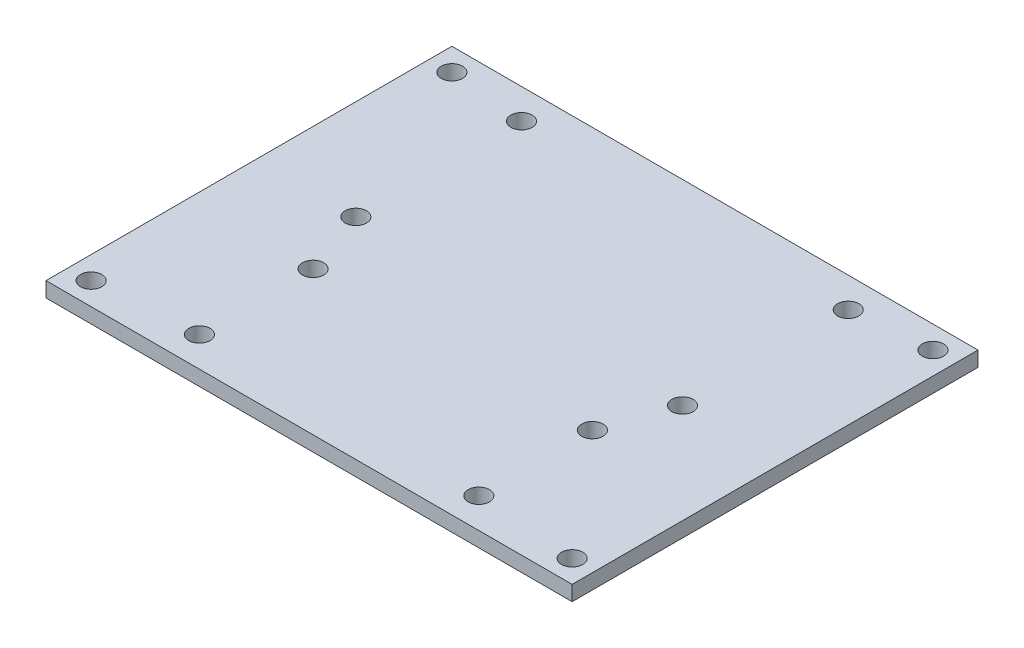
from build123d import *

# Parameters (mm, degrees)
SKETCH1_W            = 111.125
SKETCH1_H            = 85.725
BOSS_EXTRUDE1_DEPTH  = 3.175
M3_CLEARANCE_HOLE1_D = 4.5
M3_CLEARANCE_HOLE2_D = 4.5


with BuildPart() as part:
    # Sketch1 → Boss-Extrude1 (new body)
    with BuildSketch(Plane(origin=(0, 0, 0), x_dir=(1, 0, 0), z_dir=(0, 1, 0))):
        Rectangle(SKETCH1_W, SKETCH1_H)
    extrude(amount=BOSS_EXTRUDE1_DEPTH)

    # M3 Clearance Hole1 (through all)
    with Locations(Plane(origin=(-50.8, 0, 38.1), x_dir=(0, 0, -1), z_dir=(0, -1, 0))):
        with Locations((0, 0), (0, 101.6), (76.2, 0), (76.2, 101.6)):
            Hole(M3_CLEARANCE_HOLE1_D / 2)

    # M3 Clearance Hole2 (through all)
    with Locations(Plane(origin=(-29.5, 3.175, 36.5125), x_dir=(0, 0, 1), z_dir=(0, 1, 0))):
        with Locations((0, 0), (-24, 0), (-24, 59), (0, 59), (-38.025, 64), (-73.025, 64), (-73.025, -5), (-38.025, -5)):
            Hole(M3_CLEARANCE_HOLE2_D / 2)


solid = part.part
